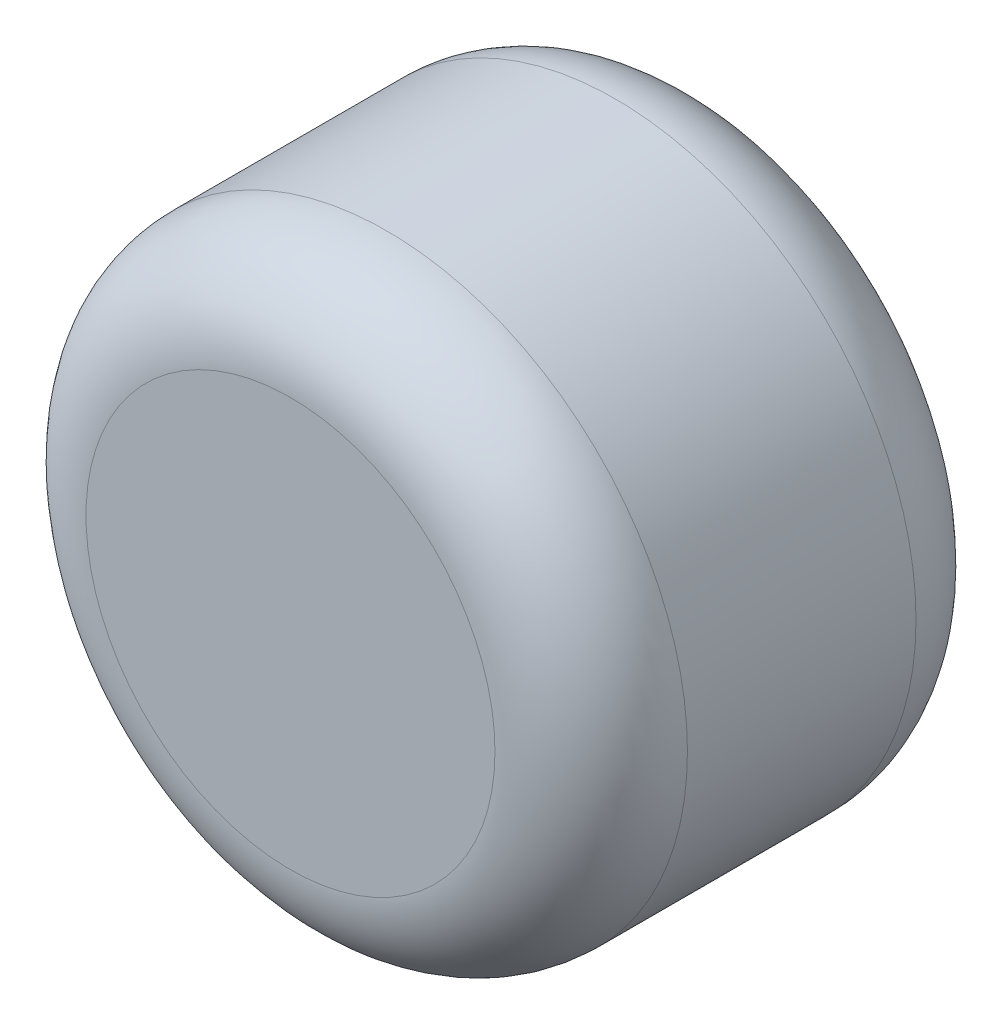
from build123d import *

# Parameters (mm, degrees)
SKETCH1_R           = 63.5
BOSS_EXTRUDE1_DEPTH = 44.45
FILLET1_R           = 20.32


with BuildPart() as part:
    # Sketch1 → Boss-Extrude1 (new body, symmetric)
    with BuildSketch(Plane.XY):
        Circle(SKETCH1_R)
    extrude(amount=BOSS_EXTRUDE1_DEPTH, both=True)

    # Fillet1
    fillet1_edges = [part.edges().sort_by_distance(p)[0] for p in [
        (-63.5, 0, -44.45),
        (-63.5, 0, 44.45),
    ]]
    fillet(fillet1_edges, radius=FILLET1_R)


solid = part.part
